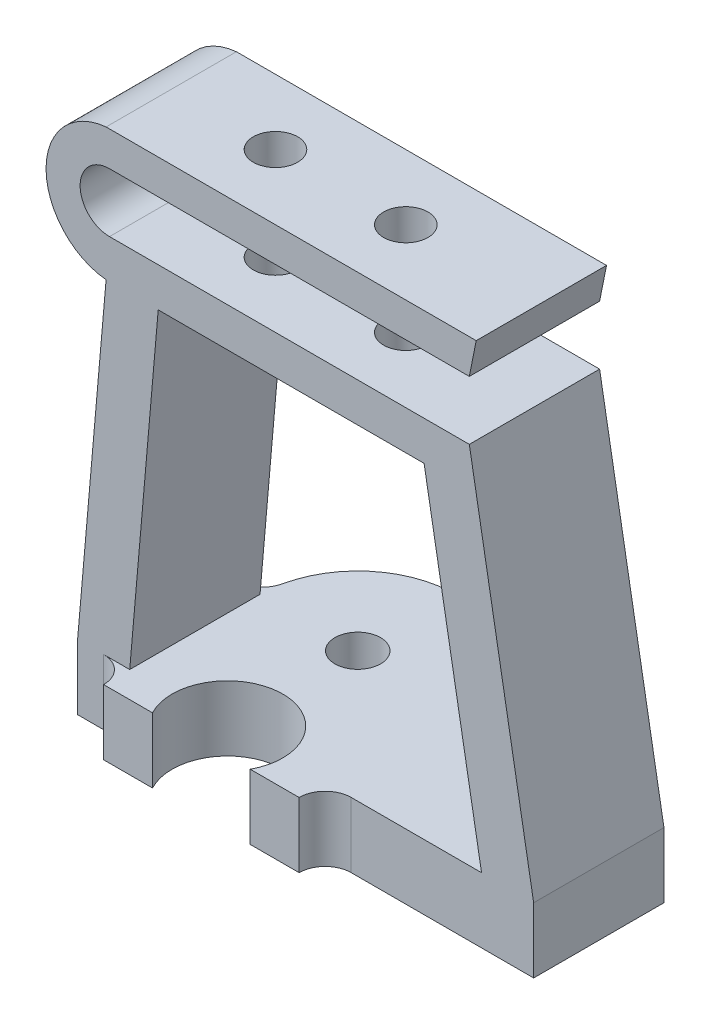
from build123d import *

# Parameters (mm, degrees)
SKETCH1_R           = 4.25
SKETCH1_R_2         = 1.75
BOSS_EXTRUDE1_DEPTH = 5
SKETCH2_W           = 20
SKETCH2_H           = 5
BOSS_EXTRUDE2_DEPTH = 16
BOSS_EXTRUDE4_START = -15
SKETCH2_2_W         = 20
SKETCH2_2_H         = 5
BOSS_EXTRUDE4_DEPTH = 4
BOSS_EXTRUDE5_DEPTH = 20
BOSS_EXTRUDE6_DEPTH = 20
CUT_EXTRUDE1_DEPTH  = 10
FILLET1_R           = 2
SKETCH8_W           = 31.663796016
SKETCH8_H           = 17.317589317
CUT_EXTRUDE2_DEPTH  = 6
SKETCH9_R           = 1.7
CUT_EXTRUDE3_DEPTH  = 10.15756


with BuildPart() as part:
    # Sketch1 → Boss-Extrude1 (new body)
    with BuildSketch(Plane(origin=(0, 0, 0), x_dir=(1, 0, 0), z_dir=(0, 1, 0))):
        with BuildLine():
            Line((-7.5, -10), (-7.5, 10))
            ThreePointArc((-7.5, 10), (0, 17.5), (7.5, 10))
            Line((7.5, 10), (7.5, -10))
            ThreePointArc((7.5, -10), (0, -17.5), (-7.5, -10))
        make_face()
        Circle(SKETCH1_R, mode=Mode.SUBTRACT)
        with Locations((0, 10)):
            Circle(SKETCH1_R_2, mode=Mode.SUBTRACT)
        with Locations((0, -10)):
            Circle(SKETCH1_R_2, mode=Mode.SUBTRACT)
    extrude(amount=BOSS_EXTRUDE1_DEPTH)

    # Sketch2 → Boss-Extrude2 (add)
    with BuildSketch(Plane(origin=(7.5, 0, 0), x_dir=(0, 0, -1), z_dir=(1, 0, 0))):
        with Locations((0, 2.5)):
            Rectangle(SKETCH2_W, SKETCH2_H)
    extrude(amount=BOSS_EXTRUDE2_DEPTH)

    # Sketch2_2 → Boss-Extrude4 (add)
    with BuildSketch(Plane(origin=(7.5, 0, 0), x_dir=(0, 0, -1), z_dir=(1, 0, 0)).offset(BOSS_EXTRUDE4_START)):
        with Locations((0, 2.5)):
            Rectangle(SKETCH2_2_W, SKETCH2_2_H)
    extrude(amount=-BOSS_EXTRUDE4_DEPTH)

    # Sketch4 → Boss-Extrude5 (add)
    with BuildSketch(Plane.XY.offset(10)):
        Polygon((-9.312783412, 30), (-11.5, 5), (-7.5, 5), (-5.312783412, 30), align=None)
        Polygon((15.091825482, 30), (19.5, 5), (23.5, 5), (19.091825482, 30), align=None)
    extrude(amount=-BOSS_EXTRUDE5_DEPTH)

    # Sketch5 → Boss-Extrude6 (add)
    with BuildSketch(Plane.XY.offset(10)):
        with BuildLine():
            Line((19.091825482, 30), (-9.312783412, 30))
            ThreePointArc((-9.312783412, 30), (-13.921057054, 35.078779792), (-9.312783412, 40.157559584))
            Line((-9.312783412, 40.157559584), (19.091825482, 40.157559584))
            Line((19.091825482, 40.157559584), (18.56284454, 37.513443833))
            Line((18.56284454, 37.513443833), (-9.050317421, 37.513443833))
            ThreePointArc((-9.050317421, 37.513443833), (-11.307039338, 35.256721917), (-9.050317421, 33))
            Line((-9.050317421, 33), (18.56284454, 33))
            Line((18.56284454, 33), (19.091825482, 30))
        make_face()
    extrude(amount=-BOSS_EXTRUDE6_DEPTH)

    # Sketch7 → Cut-Extrude1 (cut)
    with BuildSketch(Plane.XY.offset(10)):
        Polygon((-7.5, 5), (-7.5, 0), (-22.139799827, 0), (-22.139799827, 42.515854551), (27.283557157, 42.515854551), (27.283557157, 0), (7.5, 0), (7.5, 5), align=None)
    extrude(amount=-CUT_EXTRUDE1_DEPTH, mode=Mode.SUBTRACT)

    # Fillet1
    fillet1_edges = [part.edges().sort_by_distance(p)[0] for p in [
        (-7.5, 2.5, 0),
        (7.5, 2.5, 0),
        (-7.5, 2.5, -10),
        (7.5, 2.5, -10),
    ]]
    fillet(fillet1_edges, radius=FILLET1_R)

    # Sketch8 → Cut-Extrude2 (cut, through all)
    with BuildSketch(Plane(origin=(0, 5, 0), x_dir=(1, 0, 0), z_dir=(0, 1, 0))):
        with Locations((-0.714782894, -10.658794658)):
            Rectangle(SKETCH8_W, SKETCH8_H)
    extrude(amount=-CUT_EXTRUDE2_DEPTH, mode=Mode.SUBTRACT)

    # Sketch9 → Cut-Extrude3 (cut)
    with BuildSketch(Plane(origin=(0, 40.157559584, 0), x_dir=(1, 0, 0), z_dir=(0, 1, 0))):
        with Locations((-1.312783412, 5)):
            Circle(SKETCH9_R)
        with Locations((8.687216588, 5)):
            Circle(SKETCH9_R)
    extrude(amount=-CUT_EXTRUDE3_DEPTH, mode=Mode.SUBTRACT)


solid = part.part
